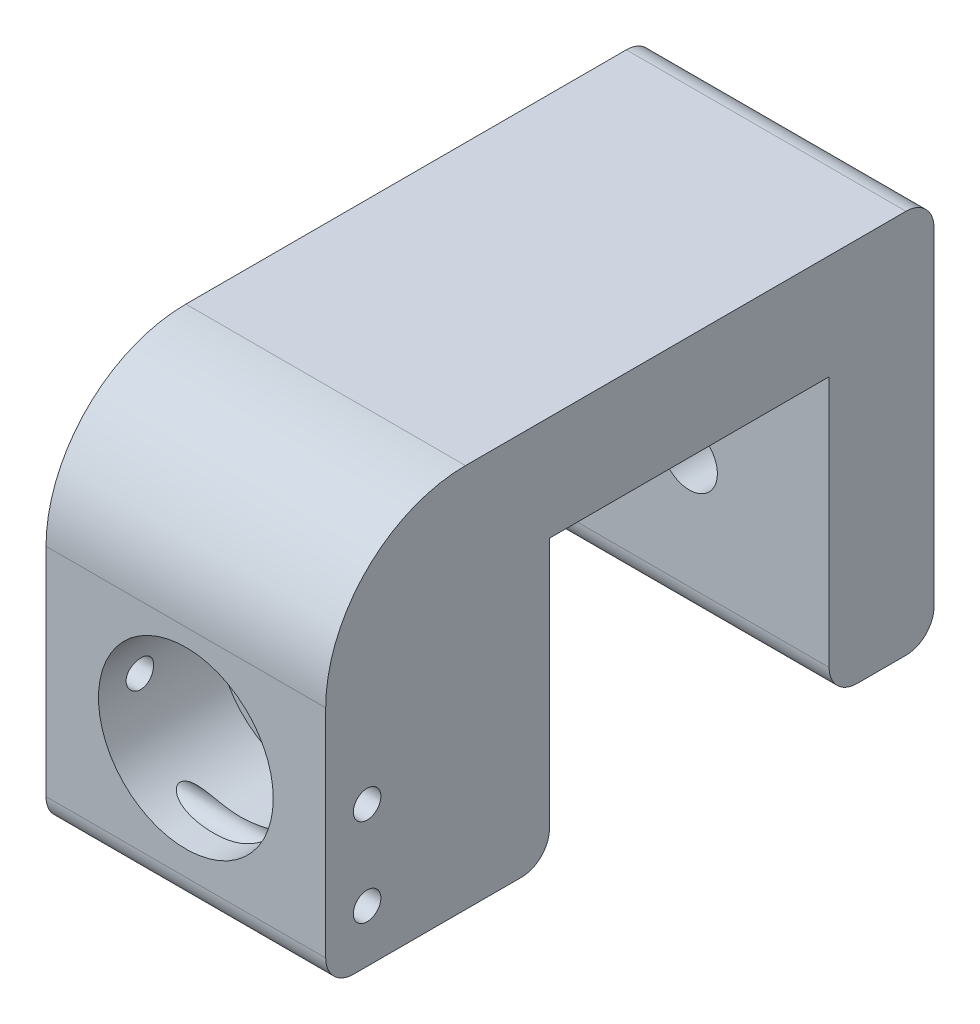
from build123d import *

# Parameters (mm, degrees)
BOSS_EXTRUDE1_DEPTH            = 25.4
F_1_4_0_2500_DOWEL_HOLE1_D     = 6.35
F_1_4_0_2500_DOWEL_HOLE1_DEPTH = 20.32
F_10_CLEARANCE_HOLE1_D         = 5.1054
SKETCH8_R                      = 7.9375
CUT_EXTRUDE1_DEPTH             = 10.795
M3X0_5_TAPPED_HOLE1_D          = 2.5
FILLET1_R                      = 2.54


with BuildPart() as part:
    # Sketch1 → Boss-Extrude1 (new body)
    with BuildSketch(Plane(origin=(0, 0, 0), x_dir=(0, 0, -1), z_dir=(1, 0, 0))):
        with BuildLine():
            Line((0, 0), (0, -25.4))
            Line((0, -25.4), (-20.32, -25.4))
            Line((-20.32, -25.4), (-20.32, -3.175))
            ThreePointArc((-20.32, -3.175), (-16.600256121, 5.805256121), (-7.62, 9.525))
            Line((-7.62, 9.525), (34.925, 9.525))
            Line((34.925, 9.525), (34.925, -25.4))
            Line((34.925, -25.4), (25.4, -25.4))
            Line((25.4, -25.4), (25.4, 0))
            Line((25.4, 0), (0, 0))
        make_face()
    extrude(amount=BOSS_EXTRUDE1_DEPTH)

    # 1/4 (0.2500) Dowel Hole1
    with Locations(Plane(origin=(0, 0, 0), x_dir=(-1, 0, 0), z_dir=(0, 0, -1))):
        with Locations((-12.7, -12.7)):
            Hole(F_1_4_0_2500_DOWEL_HOLE1_D / 2, depth=F_1_4_0_2500_DOWEL_HOLE1_DEPTH)

    # #10 Clearance Hole1 (through all)
    with Locations(Plane(origin=(0, 0, -34.925), x_dir=(-1, 0, 0), z_dir=(0, 0, -1))):
        with Locations((-12.7, -12.7)):
            Hole(F_10_CLEARANCE_HOLE1_D / 2)

    # Sketch8 → Cut-Extrude1 (cut)
    with BuildSketch(Plane.XY.offset(20.32)):
        with Locations((12.7, -12.7)):
            Circle(SKETCH8_R)
    extrude(amount=-CUT_EXTRUDE1_DEPTH, mode=Mode.SUBTRACT)

    # M3x0.5 Tapped Hole1 (through all)
    with Locations(Plane(origin=(25.4, 0, 0), x_dir=(0, 0, -1), z_dir=(1, 0, 0))):
        with Locations((-16.5608, -12.6375), (-16.5608, -20.6375)):
            Hole(M3X0_5_TAPPED_HOLE1_D / 2)

    # Fillet1
    fillet1_edges = [part.edges().sort_by_distance(p)[0] for p in [
        (12.7, -25.4, 0),
        (12.7, -25.4, 20.32),
        (12.7, 9.525, -34.925),
        (12.7, -25.4, -34.925),
        (12.7, -25.4, -25.4),
    ]]
    fillet(fillet1_edges, radius=FILLET1_R)


solid = part.part
